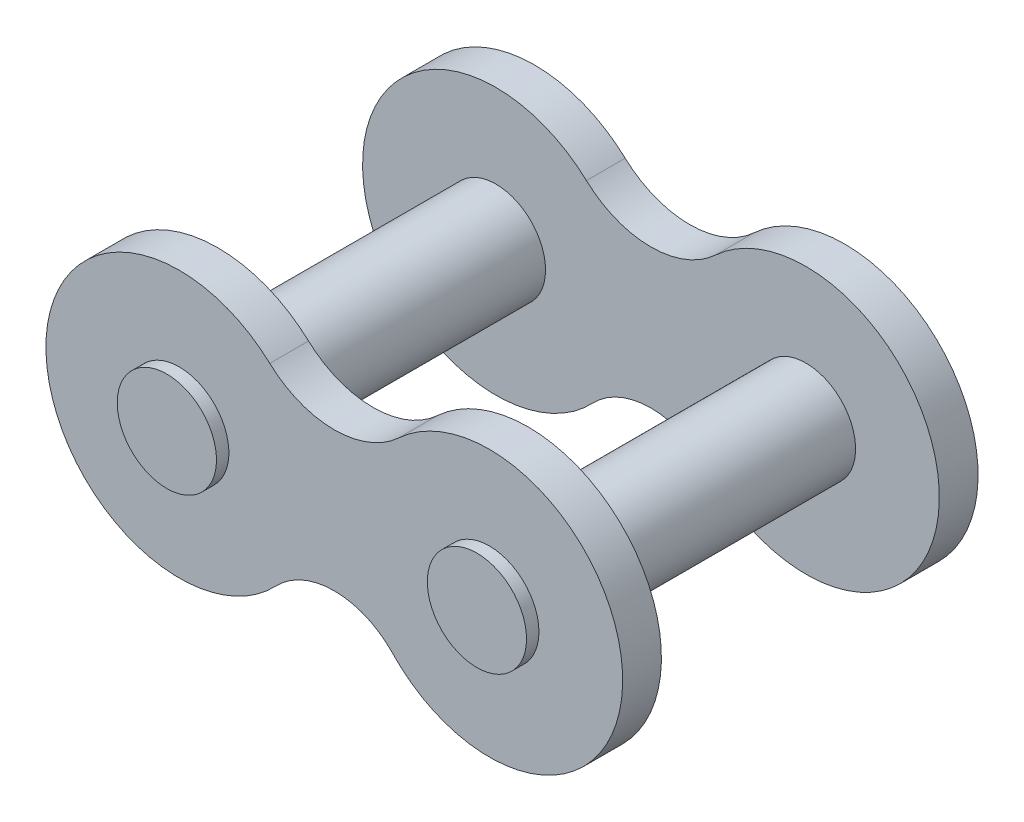
from build123d import *

# Parameters (mm, degrees)
SKETCH1_R           = 2.032
BOSS_EXTRUDE1_DEPTH = 1.5875
BOSS_EXTRUDE2_START = -15.065248
SKETCH2_R           = 2.032
BOSS_EXTRUDE2_DEPTH = 15.573248


with BuildPart() as part:
    # Sketch1 → Boss-Extrude1 (new body)
    with BuildSketch(Plane.XY):
        with BuildLine():
            ThreePointArc((-2.642212666, 4.009343348), (-11.808186134, -0.175285856), (-2.392603437, -3.763181293))
            ThreePointArc((-2.392603437, -3.763181293), (0, -2.73669663), (2.392603437, -3.763181293))
            ThreePointArc((2.392603437, -3.763181293), (11.808186134, -0.175285856), (2.642212666, 4.009343348))
            ThreePointArc((2.642212666, 4.009343348), (0, 2.974875822), (-2.642212666, 4.009343348))
        make_face()
        with Locations((-6.35, 0)):
            Circle(SKETCH1_R, mode=Mode.SUBTRACT)
        with Locations((6.35, 0)):
            Circle(SKETCH1_R, mode=Mode.SUBTRACT)
    boss_extrude1 = extrude(amount=BOSS_EXTRUDE1_DEPTH)

    # Sketch2 → Boss-Extrude2 (add)
    with BuildSketch(Plane(origin=(0, 0, 0), x_dir=(-1, 0, 0), z_dir=(0, 0, -1)).offset(BOSS_EXTRUDE2_START)):
        with Locations((6.35, 0)):
            Circle(SKETCH2_R)
    boss_extrude2 = extrude(amount=BOSS_EXTRUDE2_DEPTH)

    # Mirror2: Boss-Extrude1 across plane
    add(boss_extrude1.mirror(Plane(origin=(0, 0, 7.278624), x_dir=(1, 0, 0), z_dir=(0, 0, -1))))

    # Mirror3: Boss-Extrude2 across plane
    add(boss_extrude2.mirror(Plane(origin=(0, 0, 0), x_dir=(0, 0, 1), z_dir=(1, 0, 0))))


solid = part.part
